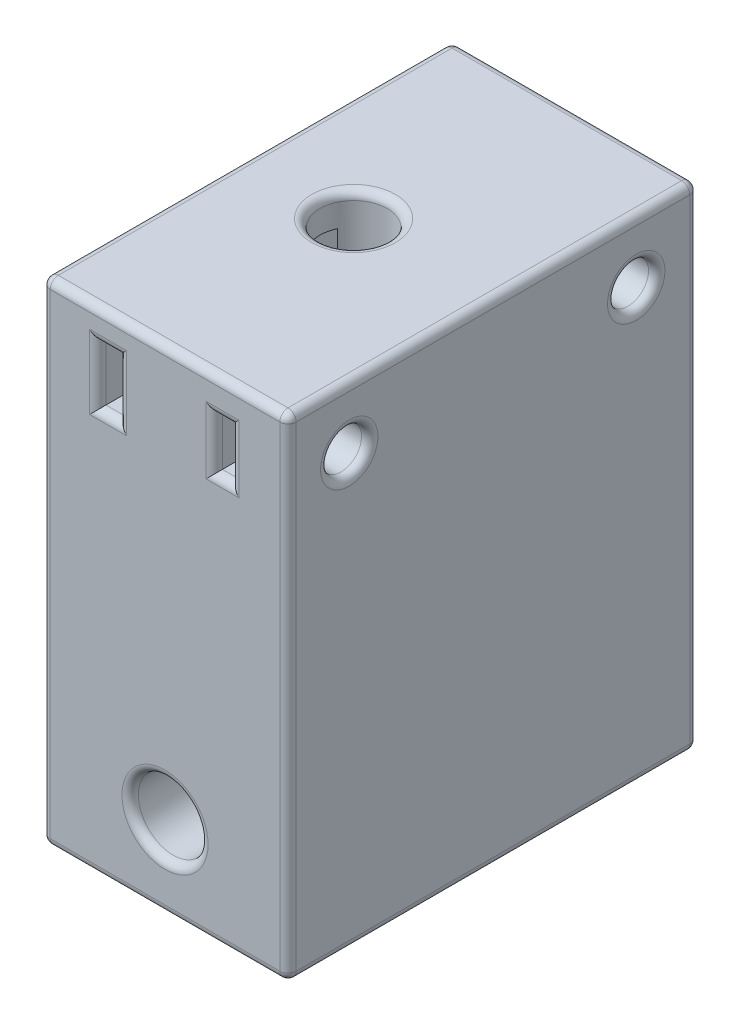
from build123d import *

# Parameters (mm, degrees)
SKETCH_1_W               = 30
SKETCH_1_H               = 60
SKETCH_1_R               = 4.25
EXTRUDE_1_DEPTH          = 50
SKETCH_2_W               = 2.5
SKETCH_2_H               = 7
SKETCH_2_W_2             = 2
SKETCH_2_H_2             = 6.2
CUT_EXTRUDE_1_DEPTH      = 50
SKETCH_4_R               = 2.5
CUT_EXTRUDE_2_DEPTH      = 1
CUT_EXTRUDE_2_DEPTH_BACK = 7
FILLET_1_R               = 1
FILLET_2_R               = 1
FILLET_3_R               = 1
FILLET_4_R               = 1
FILLET_5_R               = 1
FILLET_6_R               = 1
SKETCH_5_R               = 4.1
CUT_EXTRUDE_3_DEPTH      = 36
FILLET_7_R               = 1
FILLET_8_R               = 1


with BuildPart() as part:
    # 草图1 → 凸台-拉伸1 (new body)
    with BuildSketch(Plane.XY):
        with Locations((6.369509044, 21.447028424)):
            Rectangle(SKETCH_1_W, SKETCH_1_H)
        with Locations((6.369509044, 1.447028424)):
            Circle(SKETCH_1_R, mode=Mode.SUBTRACT)
    extrude(amount=EXTRUDE_1_DEPTH)

    # 草图2 → 切除-拉伸1 (cut)
    with BuildSketch(Plane.XY.offset(50)):
        with Locations((-0.580490956, 44.147028424)):
            Rectangle(SKETCH_2_W, SKETCH_2_H)
        with Locations((13.369509044, 44.047028424)):
            Rectangle(SKETCH_2_W_2, SKETCH_2_H_2)
    extrude(amount=-CUT_EXTRUDE_1_DEPTH, mode=Mode.SUBTRACT)

    # 草图4 → 切除-拉伸2 (cut, two sides)
    with BuildSketch(Plane(origin=(21.369509044, 0, 0), x_dir=(0, 0, -1), z_dir=(1, 0, 0))) as cut_extrude_2_sk:
        with Locations((-42.532463012, 43.947028424)):
            Circle(SKETCH_4_R)
        with Locations((-7.532463012, 43.947028424)):
            Circle(SKETCH_4_R)
    extrude(amount=CUT_EXTRUDE_2_DEPTH, mode=Mode.SUBTRACT)
    extrude(cut_extrude_2_sk.sketch, amount=-CUT_EXTRUDE_2_DEPTH_BACK, mode=Mode.SUBTRACT)

    # 圆角1
    fillet_1_edges = [part.edges().sort_by_distance(p)[0] for p in [
        (12.369509044, 44.047028424, 50),
        (13.369509044, 40.947028424, 50),
        (14.369509044, 44.047028424, 50),
        (13.369509044, 47.147028424, 50),
    ]]
    fillet(fillet_1_edges, radius=FILLET_1_R)

    # 圆角2
    fillet_2_edges = [part.edges().sort_by_distance(p)[0] for p in [
        (-1.830490956, 44.147028424, 50),
        (-0.580490956, 40.647028424, 50),
        (0.669509044, 44.147028424, 50),
        (-0.580490956, 47.647028424, 50),
    ]]
    fillet(fillet_2_edges, radius=FILLET_2_R)

    # 圆角3
    fillet_3_edges = [part.edges().sort_by_distance(p)[0] for p in [
        (2.119509044, 1.447028424, 50),
    ]]
    fillet(fillet_3_edges, radius=FILLET_3_R)

    # 圆角4
    fillet_4_edges = [part.edges().sort_by_distance(p)[0] for p in [
        (21.369509044, 43.947028424, 45.032463012),
    ]]
    fillet(fillet_4_edges, radius=FILLET_4_R)

    # 圆角5
    fillet_5_edges = [part.edges().sort_by_distance(p)[0] for p in [
        (21.369509044, 43.947028424, 10.032463012),
    ]]
    fillet(fillet_5_edges, radius=FILLET_5_R)

    # 圆角6
    fillet_6_edges = [part.edges().sort_by_distance(p)[0] for p in [
        (2.119509044, 1.447028424, 0),
        (-1.830490956, 44.147028424, 0),
        (-0.580490956, 47.647028424, 0),
        (0.669509044, 44.147028424, 0),
        (-0.580490956, 40.647028424, 0),
        (12.369509044, 44.047028424, 0),
        (13.369509044, 47.147028424, 0),
        (14.369509044, 44.047028424, 0),
        (13.369509044, 40.947028424, 0),
    ]]
    fillet(fillet_6_edges, radius=FILLET_6_R)

    # 草图5 → 切除-拉伸3 (cut)
    with BuildSketch(Plane(origin=(0, 51.447028424, 0), x_dir=(1, 0, 0), z_dir=(0, 1, 0))):
        with Locations((4.369509044, -25)):
            Circle(SKETCH_5_R)
    extrude(amount=-CUT_EXTRUDE_3_DEPTH, mode=Mode.SUBTRACT)

    # 圆角7
    fillet_7_edges = [part.edges().sort_by_distance(p)[0] for p in [
        (0.269509044, 51.447028424, 25),
    ]]
    fillet(fillet_7_edges, radius=FILLET_7_R)

    # 圆角8
    fillet_8_edges = [part.edges().sort_by_distance(p)[0] for p in [
        (21.369509044, 21.447028424, 50),
        (6.369509044, 51.447028424, 50),
        (-8.630490956, 21.447028424, 50),
        (6.369509044, 51.447028424, 0),
        (21.369509044, 21.447028424, 0),
        (6.369509044, -8.552971576, 0),
        (-8.630490956, 21.447028424, 0),
        (6.369509044, -8.552971576, 50),
        (-8.630490956, 51.447028424, 25),
        (21.369509044, 51.447028424, 25),
        (21.369509044, -8.552971576, 25),
        (-8.630490956, -8.552971576, 25),
    ]]
    fillet(fillet_8_edges, radius=FILLET_8_R)


solid = part.part
